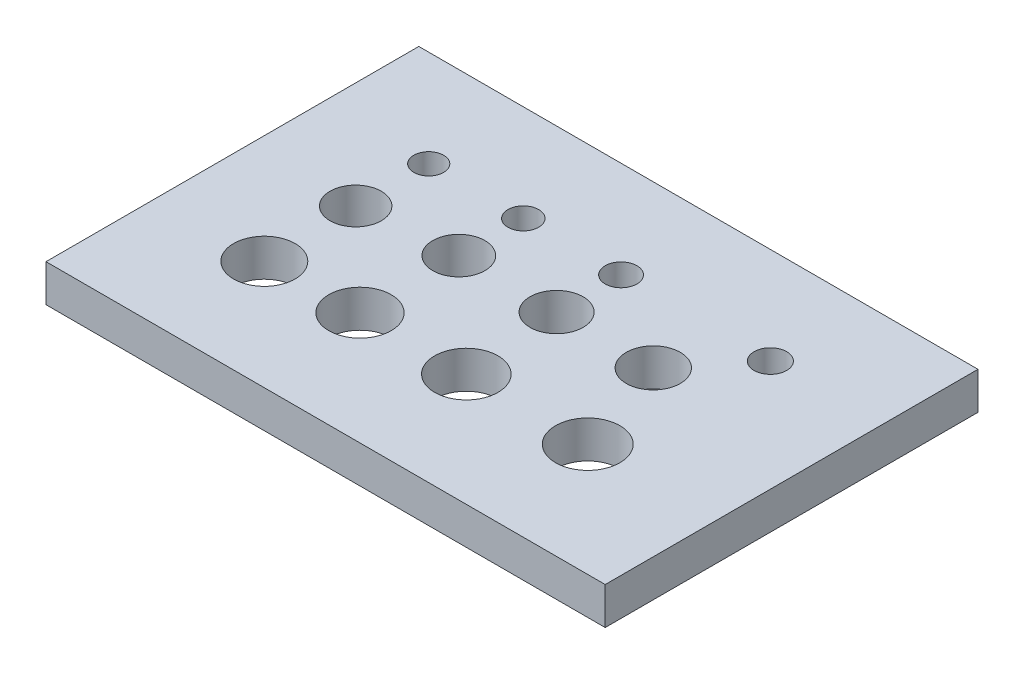
from build123d import *

# Parameters (mm, degrees)
SKETCH_1_W      = 30
SKETCH_1_H      = 20
SKETCH_1_R      = 0.8
SKETCH_1_R_2    = 0.825
SKETCH_1_R_3    = 0.85
SKETCH_1_R_4    = 0.875
SKETCH_1_R_5    = 1.375
SKETCH_1_R_6    = 1.4
SKETCH_1_R_7    = 1.425
SKETCH_1_R_8    = 1.45
SKETCH_1_R_9    = 1.65
SKETCH_1_R_10   = 1.675
SKETCH_1_R_11   = 1.7
SKETCH_1_R_12   = 1.725
EXTRUDE_1_DEPTH = 2


with BuildPart() as part:
    # 草图1 → 凸台-拉伸1 (new body)
    with BuildSketch(Plane(origin=(0, 0, 0), x_dir=(1, 0, 0), z_dir=(0, 1, 0))):
        Rectangle(SKETCH_1_W, SKETCH_1_H)
        with Locations((-9.279538905, 4.812680115)):
            Circle(SKETCH_1_R, mode=Mode.SUBTRACT)
        with Locations((-4.207492795, 4.812680115)):
            Circle(SKETCH_1_R_2, mode=Mode.SUBTRACT)
        with Locations((1.037463977, 4.812680115)):
            Circle(SKETCH_1_R_3, mode=Mode.SUBTRACT)
        with Locations((9.048991354, 4.812680115)):
            Circle(SKETCH_1_R_4, mode=Mode.SUBTRACT)
        with Locations((-9.279538905, 0.893371758)):
            Circle(SKETCH_1_R_5, mode=Mode.SUBTRACT)
        with Locations((-4.207492795, 1.354466859)):
            Circle(SKETCH_1_R_6, mode=Mode.SUBTRACT)
        with Locations((1.037463977, 1.354466859)):
            Circle(SKETCH_1_R_7, mode=Mode.SUBTRACT)
        with Locations((6.224783862, 1.354466859)):
            Circle(SKETCH_1_R_8, mode=Mode.SUBTRACT)
        with Locations((-9.161763858, -4.124789371)):
            Circle(SKETCH_1_R_9, mode=Mode.SUBTRACT)
        with Locations((-4.207492795, -3.948126801)):
            Circle(SKETCH_1_R_10, mode=Mode.SUBTRACT)
        with Locations((1.498559078, -3.948126801)):
            Circle(SKETCH_1_R_11, mode=Mode.SUBTRACT)
        with Locations((8.011527378, -3.948126801)):
            Circle(SKETCH_1_R_12, mode=Mode.SUBTRACT)
    extrude(amount=EXTRUDE_1_DEPTH)


solid = part.part
